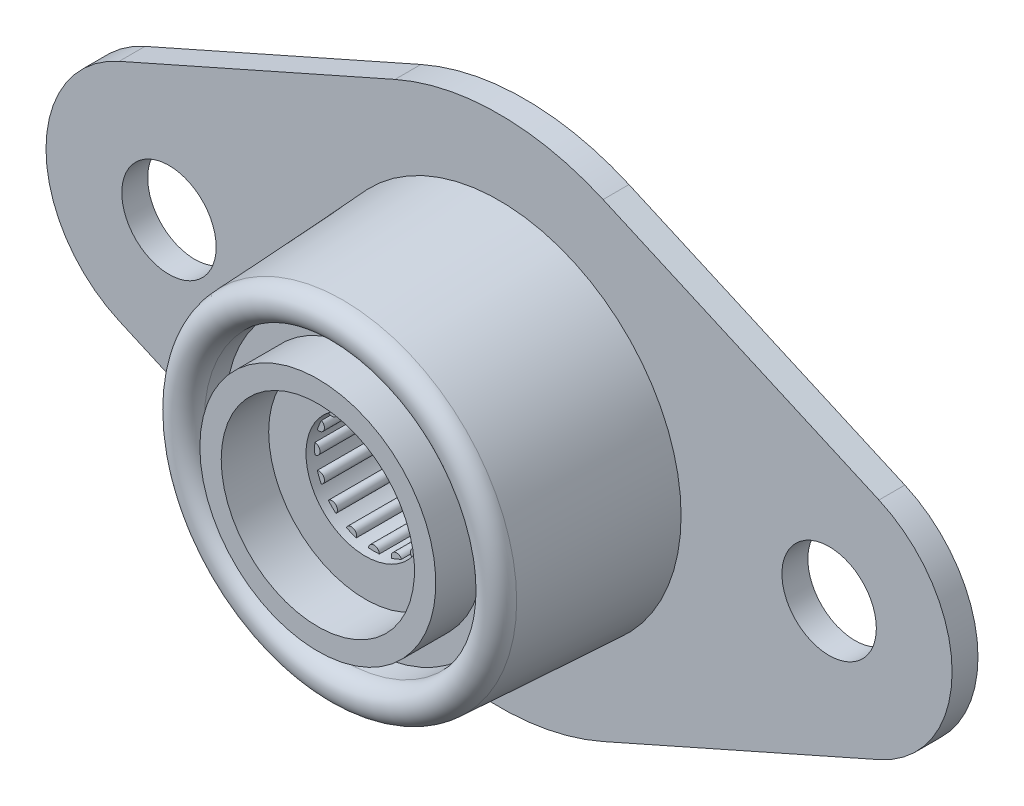
from build123d import *

# Parameters (mm, degrees)
SKETCH1_R          = 2.778125
SKETCH1_R_2        = 10.715625
EXTRUDE1_DEPTH     = 1.524
CUT_EXTRUDE2_DEPTH = 10.397303326
SKETCH4_R          = 3.4925
CUT_EXTRUDE3_DEPTH = 0.508
SKETCH5_R          = 3.4925
CUT_EXTRUDE4_DEPTH = 0.508


with BuildPart() as part:
    # Sketch1 → Extrude1 (new body)
    with BuildSketch(Plane.XY):
        with BuildLine():
            Line((-22.36445098, 6.61800471), (-6.124222222, 13.81653615))
            ThreePointArc((-6.124222222, 13.81653615), (0, 15.113), (6.124222222, 13.81653615))
            Line((6.124222222, 13.81653615), (22.36445098, 6.61800471))
            ThreePointArc((22.36445098, 6.61800471), (26.67, 0), (22.36445098, -6.61800471))
            Line((22.36445098, -6.61800471), (6.124222222, -13.81653615))
            ThreePointArc((6.124222222, -13.81653615), (0, -15.113), (-6.124222222, -13.81653615))
            Line((-6.124222222, -13.81653615), (-22.36445098, -6.61800471))
            ThreePointArc((-22.36445098, -6.61800471), (-26.67, 0), (-22.36445098, 6.61800471))
        make_face()
        with Locations((-19.431, 0)):
            Circle(SKETCH1_R, mode=Mode.SUBTRACT)
        with Locations((19.431, 0)):
            Circle(SKETCH1_R, mode=Mode.SUBTRACT)
        Circle(SKETCH1_R_2, mode=Mode.SUBTRACT)
    extrude(amount=EXTRUDE1_DEPTH)

    # Sketch2 → Revolve1 (revolve)
    with BuildSketch(Plane(origin=(0, 0, 0), x_dir=(0, 0, -1), z_dir=(1, 0, 0))):
        with BuildLine():
            Line((0, 10.715625), (-1.524, 10.715625))
            Line((-1.524, 10.715625), (-10.720513119, 10.23365617))
            ThreePointArc((-10.720513119, 10.23365617), (-11.404789036, 9.918200651), (-11.684, 9.218352844))
            ThreePointArc((-11.684, 9.218352844), (-11.386216439, 8.499439732), (-10.667303326, 8.20165617))
            Line((-10.667303326, 8.20165617), (-9.397303326, 8.20165617))
            Line((-9.397303326, 8.20165617), (-9.397303326, 6.944992128))
            Line((-9.397303326, 6.944992128), (-12.192, 6.944992128))
            Line((-12.192, 6.944992128), (-12.192, 5.688328085))
            Line((-12.192, 5.688328085), (-9.397303326, 5.688328085))
            Line((-9.397303326, 5.688328085), (-9.397303326, 4.431664043))
            Line((-9.397303326, 4.431664043), (-9.397303326, 3.175))
            Line((-9.397303326, 3.175), (0, 3.175))
            Line((0, 3.175), (0, 10.715625))
        make_face()
    revolve(axis=Axis((0, 0, 0), (0, 0, 1)))

    # Sketch3 → Cut-Extrude2 (cut, through all)
    with BuildSketch(Plane.XY.offset(9.397303326)):
        with BuildLine():
            ThreePointArc((-1.624027636, 3.0919396), (-1.940329039, 2.903907621), (-2.235091242, 2.683639952))
            ThreePointArc((-2.235091242, 2.683639952), (-2.24506403, 2.24506403), (-2.683639952, 2.235091242))
            ThreePointArc((-2.683639952, 2.235091242), (-2.903907621, 1.940329039), (-3.0919396, 1.624027636))
            ThreePointArc((-3.0919396, 1.624027636), (-2.933317516, 1.215019898), (-3.334692412, 1.037970504))
            ThreePointArc((-3.334692412, 1.037970504), (-3.425392592, 0.68135295), (-3.478068182, 0.317171835))
            ThreePointArc((-3.478068182, 0.317171835), (-3.175, 0), (-3.478068182, -0.317171835))
            ThreePointArc((-3.478068182, -0.317171835), (-3.425392592, -0.68135295), (-3.334692412, -1.037970504))
            ThreePointArc((-3.334692412, -1.037970504), (-2.933317516, -1.215019898), (-3.0919396, -1.624027636))
            ThreePointArc((-3.0919396, -1.624027636), (-2.903907621, -1.940329039), (-2.683639952, -2.235091242))
            ThreePointArc((-2.683639952, -2.235091242), (-2.24506403, -2.24506403), (-2.235091242, -2.683639952))
            ThreePointArc((-2.235091242, -2.683639952), (-1.940329039, -2.903907621), (-1.624027636, -3.0919396))
            ThreePointArc((-1.624027636, -3.0919396), (-1.215019898, -2.933317516), (-1.037970504, -3.334692412))
            ThreePointArc((-1.037970504, -3.334692412), (-0.68135295, -3.425392592), (-0.317171835, -3.478068182))
            ThreePointArc((-0.317171835, -3.478068182), (0, -3.175), (0.317171835, -3.478068182))
            ThreePointArc((0.317171835, -3.478068182), (0.68135295, -3.425392592), (1.037970504, -3.334692412))
            ThreePointArc((1.037970504, -3.334692412), (1.215019898, -2.933317516), (1.624027636, -3.0919396))
            ThreePointArc((1.624027636, -3.0919396), (1.940329039, -2.903907621), (2.235091242, -2.683639952))
            ThreePointArc((2.235091242, -2.683639952), (2.24506403, -2.24506403), (2.683639952, -2.235091242))
            ThreePointArc((2.683639952, -2.235091242), (2.903907621, -1.940329039), (3.0919396, -1.624027636))
            ThreePointArc((3.0919396, -1.624027636), (2.933317516, -1.215019898), (3.334692412, -1.037970504))
            ThreePointArc((3.334692412, -1.037970504), (3.425392592, -0.68135295), (3.478068182, -0.317171835))
            ThreePointArc((3.478068182, -0.317171835), (3.175, 0), (3.478068182, 0.317171835))
            ThreePointArc((3.478068182, 0.317171835), (3.425392592, 0.68135295), (3.334692412, 1.037970504))
            ThreePointArc((3.334692412, 1.037970504), (2.933317516, 1.215019898), (3.0919396, 1.624027636))
            ThreePointArc((3.0919396, 1.624027636), (2.903907621, 1.940329039), (2.683639952, 2.235091242))
            ThreePointArc((2.683639952, 2.235091242), (2.24506403, 2.24506403), (2.235091242, 2.683639952))
            ThreePointArc((2.235091242, 2.683639952), (1.940329039, 2.903907621), (1.624027636, 3.0919396))
            ThreePointArc((1.624027636, 3.0919396), (1.215019898, 2.933317516), (1.037970504, 3.334692412))
            ThreePointArc((1.037970504, 3.334692412), (0.68135295, 3.425392592), (0.317171835, 3.478068182))
            ThreePointArc((0.317171835, 3.478068182), (0, 3.175), (-0.317171835, 3.478068182))
            ThreePointArc((-0.317171835, 3.478068182), (-0.68135295, 3.425392592), (-1.037970504, 3.334692412))
            ThreePointArc((-1.037970504, 3.334692412), (-1.215019898, 2.933317516), (-1.624027636, 3.0919396))
        make_face()
    extrude(amount=-CUT_EXTRUDE2_DEPTH, mode=Mode.SUBTRACT)

    # Sketch4 → Cut-Extrude3 (cut)
    with BuildSketch(Plane.XY.offset(9.397303326)):
        Circle(SKETCH4_R)
    extrude(amount=-CUT_EXTRUDE3_DEPTH, mode=Mode.SUBTRACT)

    # Sketch5 → Cut-Extrude4 (cut)
    with BuildSketch(Plane(origin=(0, 0, 0), x_dir=(-1, 0, 0), z_dir=(0, 0, -1))):
        Circle(SKETCH5_R)
    extrude(amount=-CUT_EXTRUDE4_DEPTH, mode=Mode.SUBTRACT)


solid = part.part
